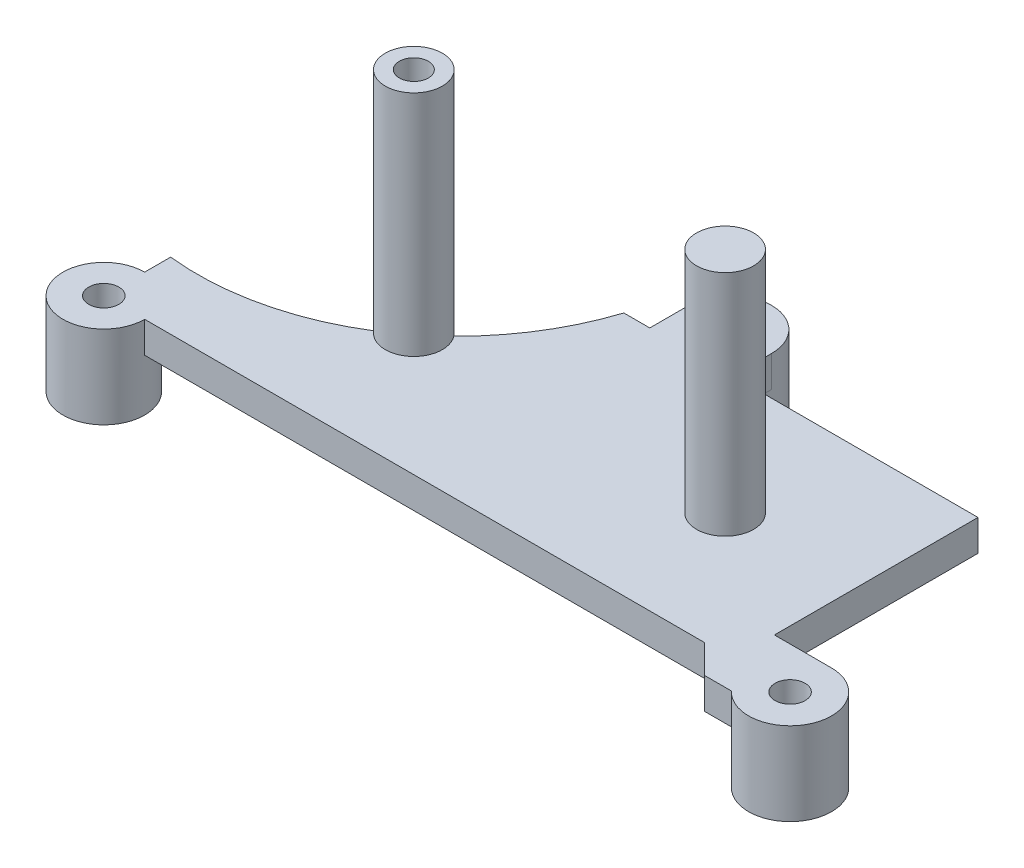
from build123d import *

# Parameters (mm, degrees)
SKETCH1_R           = 1.8415
BOSS_EXTRUDE1_DEPTH = 3.81
CUT_EXTRUDE2_DEPTH  = 3.81
SKETCH2_R           = 3.4925
BOSS_EXTRUDE2_DEPTH = 31.75
SKETCH4_R           = 5.001975
SKETCH4_R_2         = 1.8415
SKETCH4_R_3         = 5.08
BOSS_EXTRUDE3_DEPTH = 6.35
SKETCH6_R           = 1.778
CUT_EXTRUDE3_DEPTH  = 5.08


with BuildPart() as part:
    # Sketch1 → Boss-Extrude1 (new body)
    with BuildSketch(Plane(origin=(0, 0, 0), x_dir=(1, 0, 0), z_dir=(0, 1, 0))):
        with BuildLine():
            Line((35.013825, 0), (38.50005, -3.486225))
            Line((38.50005, -3.486225), (41.802802741, -3.486225))
            ThreePointArc((41.802802741, -3.486225), (50.162319809, -2.012011059), (45.49775, 5.08))
            Line((45.49775, 5.08), (38.50005, 5.08))
            Line((38.50005, 5.08), (38.50005, 29.9974))
            Line((38.50005, 29.9974), (8.48995, 29.9974))
            Line((8.48995, 29.9974), (8.48995, 34.7599))
            ThreePointArc((8.48995, 34.7599), (3.40995, 39.8399), (-1.67005, 34.7599))
            Line((-1.67005, 34.7599), (-1.67005, 29.9974))
            Line((-1.67005, 29.9974), (-38.50005, 29.9974))
            Line((-38.50005, 29.9974), (-38.50005, 5.001975))
            ThreePointArc((-38.50005, 5.001975), (-42.036980442, -3.536930442), (-33.498075, 0))
            Line((-33.498075, 0), (35.013825, 0))
        make_face()
        with Locations((3.40995, 34.7599)):
            Circle(SKETCH1_R, mode=Mode.SUBTRACT)
        with Locations((45.49775, 0)):
            Circle(SKETCH1_R, mode=Mode.SUBTRACT)
        with Locations((-38.50005, 0)):
            Circle(SKETCH1_R, mode=Mode.SUBTRACT)
    extrude(amount=BOSS_EXTRUDE1_DEPTH)

    # Sketch3 → Cut-Extrude2 (cut)
    with BuildSketch(Plane(origin=(0, 0, 0), x_dir=(1, 0, 0), z_dir=(0, 1, 0))):
        with BuildLine():
            Line((-38.50005, 8.176975), (-38.50005, 29.9974))
            Line((-38.50005, 29.9974), (-4.84505, 29.9974))
            ThreePointArc((-4.84505, 29.9974), (-17.79061216, 13.099833084), (-38.50005, 8.176975))
        make_face()
    extrude(amount=CUT_EXTRUDE2_DEPTH, mode=Mode.SUBTRACT)

    # Sketch2 → Boss-Extrude2 (add)
    with BuildSketch(Plane(origin=(0, 0, 0), x_dir=(1, 0, 0), z_dir=(0, 1, 0))):
        with Locations((-15.55115, 14.9963886)):
            Circle(SKETCH2_R)
        with Locations((22.54885, 14.9963886)):
            Circle(SKETCH2_R)
    extrude(amount=BOSS_EXTRUDE2_DEPTH)

    # Sketch4 → Boss-Extrude3 (add)
    with BuildSketch(Plane.XZ):
        with Locations((-38.50005, 0)):
            Circle(SKETCH4_R)
        with Locations((-38.50005, 0)):
            Circle(SKETCH4_R_2, mode=Mode.SUBTRACT)
        with Locations((45.49775, 0)):
            Circle(SKETCH4_R_3)
        with Locations((45.49775, 0)):
            Circle(SKETCH4_R_2, mode=Mode.SUBTRACT)
        with Locations((3.40995, -34.7599)):
            Circle(SKETCH4_R_3)
        with Locations((3.40995, -34.7599)):
            Circle(SKETCH4_R_2, mode=Mode.SUBTRACT)
    extrude(amount=BOSS_EXTRUDE3_DEPTH)

    # Sketch6 → Cut-Extrude3 (cut)
    with BuildSketch(Plane(origin=(0, 31.75, 0), x_dir=(1, 0, 0), z_dir=(0, 1, 0))):
        with Locations((-15.55115, 14.9963886)):
            Circle(SKETCH6_R)
    extrude(amount=-CUT_EXTRUDE3_DEPTH, mode=Mode.SUBTRACT)


solid = part.part
